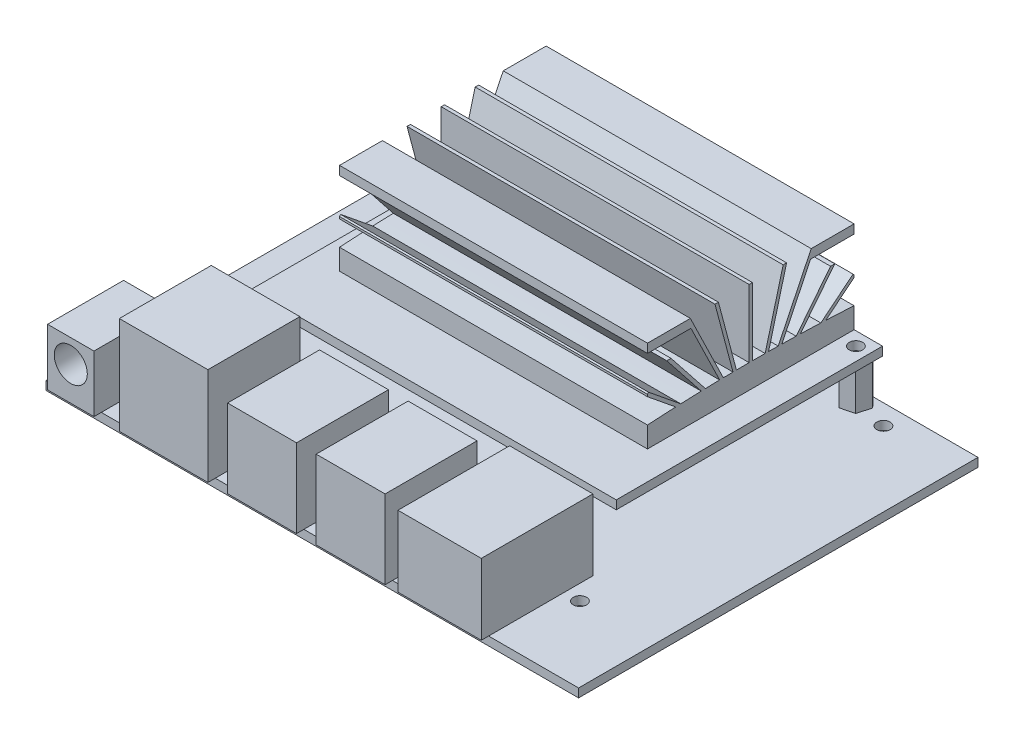
from build123d import *

# Parameters (mm, degrees)
SKETCH1_W           = 101.6
SKETCH1_H           = 76.2
SKETCH1_R           = 1.27
BOSS_EXTRUDE1_DEPTH = 1.651
BOSS_EXTRUDE2_START = 9.271
SKETCH1_3_W         = 69.596
SKETCH1_3_H         = 50.8
SKETCH1_3_R         = 1.27
BOSS_EXTRUDE2_DEPTH = 1.651
BOSS_EXTRUDE3_DEPTH = 7.62
BOSS_EXTRUDE4_DEPTH = 29.375
SKETCH5_W           = 15.9
SKETCH5_H           = 19.9
SKETCH5_H_2         = 1.4
BOSS_EXTRUDE5_DEPTH = 13.53
SKETCH5_3_W         = 13.15
SKETCH5_3_H         = 16.14
SKETCH5_3_H_2       = 1.4
BOSS_EXTRUDE6_DEPTH = 15
SKETCH5_4_W         = 16.9
SKETCH5_4_H         = 16.14
SKETCH5_4_H_2       = 1.4
BOSS_EXTRUDE7_DEPTH = 18.63
SKETCH5_5_W         = 8.85
SKETCH5_5_H         = 13.1
SKETCH5_5_H_2       = 1.4
BOSS_EXTRUDE8_DEPTH = 10.84
SKETCH6_R           = 3.155
CUT_EXTRUDE1_DEPTH  = 6.35


with BuildPart() as part:
    # Sketch1 → Boss-Extrude1 (new body)
    with BuildSketch(Plane(origin=(0, 0, 0), x_dir=(1, 0, 0), z_dir=(0, 1, 0))):
        with Locations((50.8, 38.1)):
            Rectangle(SKETCH1_W, SKETCH1_H)
        with Locations((3.81, 14.478)):
            Circle(SKETCH1_R, mode=Mode.SUBTRACT)
        with Locations((87.376, 14.478)):
            Circle(SKETCH1_R, mode=Mode.SUBTRACT)
        with Locations((3.81, 72.39)):
            Circle(SKETCH1_R, mode=Mode.SUBTRACT)
        with Locations((87.376, 72.39)):
            Circle(SKETCH1_R, mode=Mode.SUBTRACT)
        with Locations((80.8482, 73.66)):
            Circle(SKETCH1_R, mode=Mode.SUBTRACT)
        with Locations((16.3322, 73.66)):
            Circle(SKETCH1_R, mode=Mode.SUBTRACT)
    extrude(amount=BOSS_EXTRUDE1_DEPTH)



with BuildPart() as body_2:
    # Sketch1_3 → Boss-Extrude2 (new body)
    with BuildSketch(Plane(origin=(0, 0, 0), x_dir=(1, 0, 0), z_dir=(0, 1, 0)).offset(BOSS_EXTRUDE2_START)):
        with Locations((48.5902, 50.8)):
            Rectangle(SKETCH1_3_W, SKETCH1_3_H)
        with Locations((16.3322, 73.66)):
            Circle(SKETCH1_3_R, mode=Mode.SUBTRACT)
        with Locations((80.8482, 73.66)):
            Circle(SKETCH1_3_R, mode=Mode.SUBTRACT)
    extrude(amount=BOSS_EXTRUDE2_DEPTH)


with BuildPart() as part_1:
    add(part.part)

    add(body_2.part)  # Boss-Extrude3 merges body 2
    # Sketch3 → Boss-Extrude3 (add)
    with BuildSketch(Plane(origin=(0, 1.651, 0), x_dir=(1, 0, 0), z_dir=(0, 1, 0))):
        Polygon((79.007705719, 75.552170395), (78.28928523, 73.012170395), (80.12977951, 71.12), (82.688694281, 71.767829605), (83.40711477, 74.307829605), (81.56662049, 76.2), align=None)
        Polygon((17.05062049, 76.2), (14.491705719, 75.552170395), (13.77328523, 73.012170395), (15.61377951, 71.12), (18.172694281, 71.767829605), (18.89111477, 74.307829605), align=None)
    extrude(amount=BOSS_EXTRUDE3_DEPTH)

    # Sketch5 → Boss-Extrude5 (add)
    with BuildSketch(Plane(origin=(0, 1.651, 0), x_dir=(1, 0, 0), z_dir=(0, 1, 0))):
        with Locations((76.49, 9.95)):
            Rectangle(SKETCH5_W, SKETCH5_H)
        with Locations((76.49, -0.7)):
            Rectangle(SKETCH5_W, SKETCH5_H_2)
    extrude(amount=BOSS_EXTRUDE5_DEPTH)

    # Sketch5_3 → Boss-Extrude6 (add)
    with BuildSketch(Plane(origin=(0, 1.651, 0), x_dir=(1, 0, 0), z_dir=(0, 1, 0))):
        with Locations((59.515, 8.07)):
            Rectangle(SKETCH5_3_W, SKETCH5_3_H)
        with Locations((42.615, 8.07)):
            Rectangle(SKETCH5_3_W, SKETCH5_3_H)
        with Locations((42.615, -0.7)):
            Rectangle(SKETCH5_3_W, SKETCH5_3_H_2)
        with Locations((59.515, -0.7)):
            Rectangle(SKETCH5_3_W, SKETCH5_3_H_2)
    extrude(amount=BOSS_EXTRUDE6_DEPTH)

    # Sketch5_4 → Boss-Extrude7 (add)
    with BuildSketch(Plane(origin=(0, 1.651, 0), x_dir=(1, 0, 0), z_dir=(0, 1, 0))):
        with Locations((23.84, 8.07)):
            Rectangle(SKETCH5_4_W, SKETCH5_4_H)
        with Locations((23.84, -0.7)):
            Rectangle(SKETCH5_4_W, SKETCH5_4_H_2)
    extrude(amount=BOSS_EXTRUDE7_DEPTH)

    # Sketch5_5 → Boss-Extrude8 (add)
    with BuildSketch(Plane(origin=(0, 1.651, 0), x_dir=(1, 0, 0), z_dir=(0, 1, 0))):
        with Locations((6.125, 6.55)):
            Rectangle(SKETCH5_5_W, SKETCH5_5_H)
        with Locations((6.125, -0.7)):
            Rectangle(SKETCH5_5_W, SKETCH5_5_H_2)
    extrude(amount=BOSS_EXTRUDE8_DEPTH)

    # Sketch6 → Cut-Extrude1 (cut)
    with BuildSketch(Plane.XY.offset(1.4)):
        with Locations((6.125, 8.066)):
            Circle(SKETCH6_R)
    extrude(amount=-CUT_EXTRUDE1_DEPTH, mode=Mode.SUBTRACT)


with BuildPart() as body_2_2:
    # Sketch4 → Boss-Extrude4 (new body, symmetric)
    with BuildSketch(Plane(origin=(48.5902, 0, 0), x_dir=(0, 0, -1), z_dir=(1, 0, 0))):
        with BuildLine():
            ThreePointArc((56.8071, 15.493841975), (56.64835002, 15.493960494), (56.4896, 15.494))
            Line((56.4896, 15.494), (56.4896, 10.922))
            Line((56.4896, 10.922), (56.8071, 10.922))
            Line((56.8071, 10.922), (56.8071, 15.493841975))
        make_face()
        with BuildLine():
            ThreePointArc((59.227674474, 15.482247307), (58.017398236, 15.490340908), (56.8071, 15.493841975))
            Line((56.8071, 15.493841975), (56.8071, 10.922))
            Line((56.8071, 10.922), (58.015690018, 10.922))
            Line((58.015690018, 10.922), (59.227674474, 15.482247307))
        make_face()
        with BuildLine():
            ThreePointArc((59.88304407, 15.4759477), (59.55536089, 15.479265837), (59.227674474, 15.482247307))
            Line((59.227674474, 15.482247307), (58.015690018, 10.922))
            Line((58.015690018, 10.922), (58.672733871, 10.922))
            Line((58.672733871, 10.922), (59.88304407, 15.4759477))
        make_face()
        with BuildLine():
            ThreePointArc((61.723247313, 15.45105852), (60.803163642, 15.464830355), (59.88304407, 15.4759477))
            Line((59.88304407, 15.4759477), (58.672733871, 10.922))
            Line((58.672733871, 10.922), (59.524466462, 10.922))
            Line((59.524466462, 10.922), (61.723247313, 15.45105852))
        make_face()
        with BuildLine():
            ThreePointArc((62.423175033, 15.438803782), (62.073214535, 15.445123173), (61.723247313, 15.45105852))
            Line((61.723247313, 15.45105852), (59.524466462, 10.922))
            Line((59.524466462, 10.922), (60.23034365, 10.922))
            Line((60.23034365, 10.922), (62.423175033, 15.438803782))
        make_face()
        with BuildLine():
            ThreePointArc((65.144619274, 15.376549489), (63.783963568, 15.410579945), (62.423175033, 15.438803782))
            Line((62.423175033, 15.438803782), (60.23034365, 10.922))
            Line((60.23034365, 10.922), (61.61452049, 10.922))
            Line((61.61452049, 10.922), (65.144619274, 15.376549489))
        make_face()
        with BuildLine():
            ThreePointArc((65.937010991, 15.354054232), (65.540822121, 15.36554803), (65.144619274, 15.376549489))
            Line((65.144619274, 15.376549489), (61.61452049, 10.922))
            Line((61.61452049, 10.922), (62.424739033, 10.922))
            Line((62.424739033, 10.922), (65.937010991, 15.354054232))
        make_face()
        with BuildLine():
            ThreePointArc((69.852093254, 15.213970006), (67.894767198, 15.290023062), (65.937010991, 15.354054232))
            Line((65.937010991, 15.354054232), (62.424739033, 10.922))
            Line((62.424739033, 10.922), (64.571619241, 10.922))
            Line((64.571619241, 10.922), (69.852093254, 15.213970006))
        make_face()
        with BuildLine():
            ThreePointArc((70.807789081, 15.172460737), (70.329956729, 15.193573656), (69.852093254, 15.213970006))
            Line((69.852093254, 15.213970006), (64.571619241, 10.922))
            Line((64.571619241, 10.922), (65.578384534, 10.922))
            Line((65.578384534, 10.922), (70.807789081, 15.172460737))
        make_face()
        with BuildLine():
            ThreePointArc((76.2, 14.8844), (73.504504156, 15.039841776), (70.807789081, 15.172460737))
            Line((70.807789081, 15.172460737), (65.578384534, 10.922))
            Line((65.578384534, 10.922), (76.2, 10.922))
            Line((76.2, 10.922), (76.2, 14.8844))
        make_face()
        with BuildLine():
            Line((75.998202367, 20.20952834), (69.852093254, 15.213970006))
            ThreePointArc((69.852093254, 15.213970006), (70.329956729, 15.193573656), (70.807789081, 15.172460737))
            Line((70.807789081, 15.172460737), (76.2, 19.555250515))
            Line((76.2, 19.555250515), (76.2, 19.961253736))
            Line((76.2, 19.961253736), (75.998202367, 20.20952834))
        make_face()
        with BuildLine():
            Line((71.702675027, 23.652007398), (65.144619274, 15.376549489))
            ThreePointArc((65.144619274, 15.376549489), (65.540822121, 15.36554803), (65.937010991, 15.354054232))
            Line((65.937010991, 15.354054232), (72.512893571, 23.652007398))
            Line((72.512893571, 23.652007398), (71.702675027, 23.652007398))
        make_face()
        with BuildLine():
            Line((67.329152638, 26.998127105), (61.723247313, 15.45105852))
            ThreePointArc((61.723247313, 15.45105852), (62.073214535, 15.445123173), (62.423175033, 15.438803782))
            Line((62.423175033, 15.438803782), (67.900392235, 26.7208))
            Line((67.900392235, 26.7208), (76.2, 26.7208))
            Line((76.2, 26.7208), (76.2, 28.4099))
            Line((76.2, 28.4099), (68.014544358, 28.4099))
            Line((68.014544358, 28.4099), (67.329152638, 26.998127105))
        make_face()
        with BuildLine():
            Line((62.663478074, 28.4099), (59.227674474, 15.482247307))
            ThreePointArc((59.227674474, 15.482247307), (59.55536089, 15.479265837), (59.88304407, 15.4759477))
            Line((59.88304407, 15.4759477), (63.320055125, 28.408143601))
            Line((63.320055125, 28.408143601), (63.320521926, 28.4099))
            Line((63.320521926, 28.4099), (62.663478074, 28.4099))
        make_face()
        with BuildLine():
            Line((56.4896, 28.4099), (56.4896, 15.494))
            ThreePointArc((56.4896, 15.494), (56.64835002, 15.493960494), (56.8071, 15.493841975))
            Line((56.8071, 15.493841975), (56.8071, 28.4099))
            Line((56.8071, 28.4099), (56.4896, 28.4099))
        make_face()
    extrude(amount=BOSS_EXTRUDE4_DEPTH, both=True)

    # Mirror2: body 2 2 across plane


with BuildPart() as body_2_2_1:
    add(body_2_2.part)
    add(body_2_2.part.mirror(Plane(origin=(77.9652, 0, -56.4896), x_dir=(1, 0, 0), z_dir=(0, 0, 1))))


solid = Compound([part_1.part, body_2_2_1.part])
